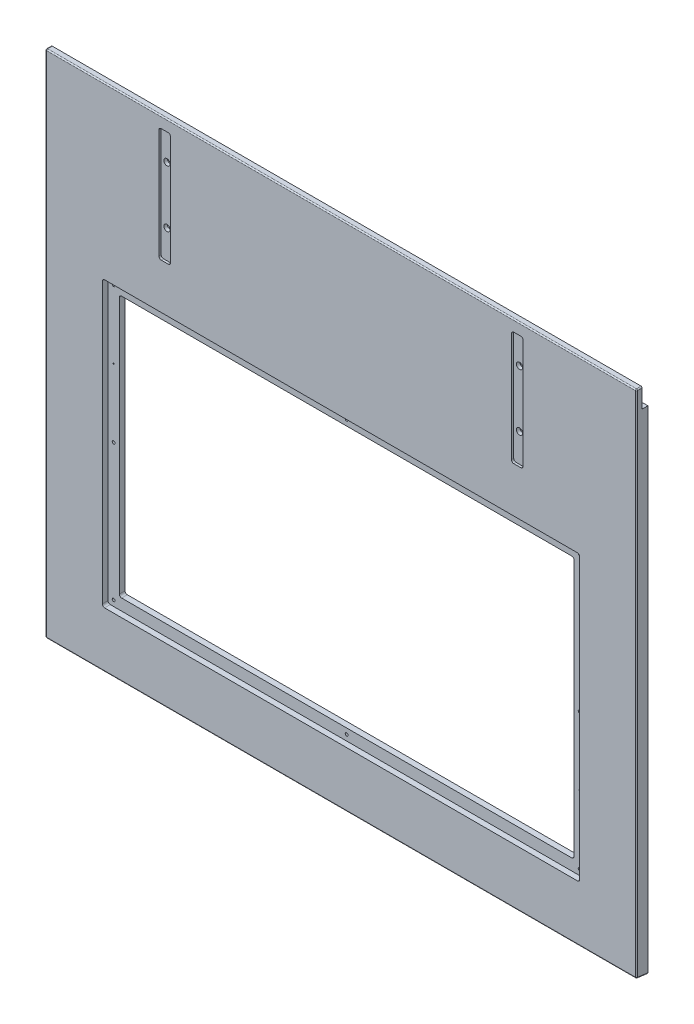
from build123d import *

# Parameters (mm, degrees)
SKETCH2_W                      = 520
SKETCH2_H                      = 450
BOSS_EXTRUDE2_DEPTH            = 10
SKETCH3_W                      = 10.2
SKETCH3_H                      = 100.2
CUT_EXTRUDE1_DEPTH             = 2
FILLET2_R                      = 2
CBORE_FOR_M5_SHCS1_D           = 5.5
CBORE_FOR_M5_SHCS1_CBORE_D     = 10
CBORE_FOR_M5_SHCS1_CBORE_DEPTH = 5
FILLET2_OF_MIRROR8_R           = 2
SKETCH7_W                      = 400
SKETCH7_H                      = 230
CUT_EXTRUDE3_DEPTH             = 469.828326789
FILLET3_R                      = 2
SKETCH9_W                      = 420
SKETCH9_H                      = 250
CUT_EXTRUDE5_DEPTH             = 5
FILLET4_R                      = 2
M3_TAPPED_HOLE1_D              = 2.5
CUT_EXTRUDE8_DEPTH             = 6
CUT_EXTRUDE7_DEPTH             = 469.828326789
CUT_EXTRUDE7_DEPTH_BACK        = 469.828326789
SKETCH11_W                     = 5
SKETCH11_H                     = 17
FILLET1_R                      = 1
M5X0_8_TAPPED_HOLE1_D          = 4.2
M5X0_8_TAPPED_HOLE1_DEPTH      = 8
M5X0_8_TAPPED_HOLE1_TIP        = 1.2618073
SKETCH17_W                     = 19
SKETCH17_H                     = 27
CUT_EXTRUDE9_DEPTH             = 2
FILLET5_R                      = 2
M4X0_7_TAPPED_HOLE1_AT_2_COUNT = 2
M4X0_7_TAPPED_HOLE1_AT_2_PITCH = 15
FILLET5_OF_MIRROR10_R          = 2
F_1_0MM_DOWEL_HOLE1_D          = 1
F_1_0MM_DOWEL_HOLE1_DEPTH      = 4
F_1_0MM_DOWEL_HOLE1_TIP        = 0.30043031


with BuildPart() as part:
    # Sketch2 → Boss-Extrude2 (new body)
    with BuildSketch(Plane.XY):
        with Locations((0, -165)):
            Rectangle(SKETCH2_W, SKETCH2_H)
    extrude(amount=-BOSS_EXTRUDE2_DEPTH)

    # Sketch3 → Cut-Extrude1 (cut)
    with BuildSketch(Plane.XY):
        with Locations((-155.1, 0)):
            Rectangle(SKETCH3_W, SKETCH3_H)
    cut_extrude1 = extrude(amount=-CUT_EXTRUDE1_DEPTH, mode=Mode.SUBTRACT)

    # Fillet2
    fillet2_edges = [part.edges().sort_by_distance(p)[0] for p in [
        (-160.2, -50.1, -1),
        (-150, -50.1, -1),
        (-150, 50.1, -1),
        (-160.2, 50.1, -1),
    ]]
    fillet(fillet2_edges, radius=FILLET2_R)

    # CBORE for M5 SHCS1 (through all)
    with Locations(Plane(origin=(0, 0, -10), x_dir=(-1, 0, 0), z_dir=(0, 0, -1))):
        with Locations((155.1, 25), (155.1, -25)):
            cbore_for_m5_shcs1 = CounterBoreHole(CBORE_FOR_M5_SHCS1_D / 2, CBORE_FOR_M5_SHCS1_CBORE_D / 2, CBORE_FOR_M5_SHCS1_CBORE_DEPTH)

    # Mirror8: Cut-Extrude1, CBORE for M5 SHCS1 across plane
    add(cut_extrude1.mirror(Plane(origin=(0, 0, 0), x_dir=(0, 0, 1), z_dir=(1, 0, 0))), mode=Mode.SUBTRACT)
    add(cbore_for_m5_shcs1.mirror(Plane(origin=(0, 0, 0), x_dir=(0, 0, 1), z_dir=(1, 0, 0))), mode=Mode.SUBTRACT)

    # Fillet2 of Mirror8
    fillet2_of_mirror8_edges = [part.edges().sort_by_distance(p)[0] for p in [
        (160.2, -50.1, -1),
        (150, -50.1, -1),
        (150, 50.1, -1),
        (160.2, 50.1, -1),
    ]]
    fillet(fillet2_of_mirror8_edges, radius=FILLET2_OF_MIRROR8_R)

    # Sketch7 → Cut-Extrude3 (cut, through all)
    with BuildSketch(Plane.XY):
        with Locations((0, -215)):
            Rectangle(SKETCH7_W, SKETCH7_H)
    extrude(amount=-CUT_EXTRUDE3_DEPTH, mode=Mode.SUBTRACT)

    # Fillet3
    fillet3_edges = [part.edges().sort_by_distance(p)[0] for p in [
        (200, -330, -5),
        (200, -100, -5),
        (-200, -330, -5),
        (-200, -100, -5),
    ]]
    fillet(fillet3_edges, radius=FILLET3_R)

    # Sketch9 → Cut-Extrude5 (cut)
    with BuildSketch(Plane.XY):
        with Locations((0, -215)):
            Rectangle(SKETCH9_W, SKETCH9_H)
    extrude(amount=-CUT_EXTRUDE5_DEPTH, mode=Mode.SUBTRACT)

    # Fillet4
    fillet4_edges = [part.edges().sort_by_distance(p)[0] for p in [
        (210, -90, -2.5),
        (210, -340, -2.5),
        (-210, -340, -2.5),
        (-210, -90, -2.5),
    ]]
    fillet(fillet4_edges, radius=FILLET4_R)

    # M3 Tapped Hole1 (through all)
    with Locations(Plane.XY.offset(-5)):
        with Locations((-205, -95), (0, -95), (-205, -215), (205, -95), (205, -215), (205, -335), (0, -335), (-205, -335)):
            Hole(M3_TAPPED_HOLE1_D / 2)

    # Sketch12 → Cut-Extrude8 (cut)
    with BuildSketch(Plane(origin=(0, 0, -10), x_dir=(-1, 0, 0), z_dir=(0, 0, -1))):
        with BuildLine():
            Line((10, -390), (-10, -390))
            Line((-10, -390), (-10, -386.5))
            ThreePointArc((-10, -386.5), (-9.267766953, -384.732233047), (-7.5, -384))
            Line((-7.5, -384), (7.5, -384))
            ThreePointArc((7.5, -384), (9.267766953, -384.732233047), (10, -386.5))
            Line((10, -386.5), (10, -390))
        make_face()
    extrude(amount=-CUT_EXTRUDE8_DEPTH, mode=Mode.SUBTRACT)

    # Sketch11 → Cut-Extrude7 (cut, two sides: drawn at the far end of the back side and taken through both)
    with BuildSketch(Plane(origin=(0, 0, 0), x_dir=(0, 0, -1), z_dir=(1, 0, 0)).offset(-CUT_EXTRUDE7_DEPTH_BACK)):
        Polygon((10, -390), (0, -388.685250563), (0, -390), align=None)
        with Locations((7.5, 51.5)):
            Rectangle(SKETCH11_W, SKETCH11_H)
    extrude(amount=CUT_EXTRUDE7_DEPTH + CUT_EXTRUDE7_DEPTH_BACK, mode=Mode.SUBTRACT)

    # Fillet1
    fillet1_edges = [part.edges().sort_by_distance(p)[0] for p in [
        (-260, 60, -2.5),
        (260, 60, -2.5),
        (260, -389.342625282, -5),
        (-260, -389.342625282, -5),
        (0, 60, 0),
        (-260, -164.342625282, 0),
        (0, -388.685250563, 0),
        (260, -164.342625282, 0),
    ]]
    fillet(fillet1_edges, radius=FILLET1_R)

    # M5x0.8 Tapped Hole1
    with Locations(Plane(origin=(0, 0, -10), x_dir=(-1, 0, 0), z_dir=(0, 0, -1))):
        with Locations((-215, 34), (-190, 34), (-12.5, 34), (12.5, 34), (190, 34), (215, 34)):
            Hole(M5X0_8_TAPPED_HOLE1_D / 2, depth=M5X0_8_TAPPED_HOLE1_DEPTH)
            with Locations((0, 0, -(M5X0_8_TAPPED_HOLE1_DEPTH + M5X0_8_TAPPED_HOLE1_TIP / 2))):  # 118° drill point
                Cone(0, M5X0_8_TAPPED_HOLE1_D / 2, M5X0_8_TAPPED_HOLE1_TIP, mode=Mode.SUBTRACT)

    # Sketch17 → Cut-Extrude9 (cut)
    with BuildSketch(Plane(origin=(0, 0, -10), x_dir=(-1, 0, 0), z_dir=(0, 0, -1))):
        with Locations((143.85, -376.5)):
            Rectangle(SKETCH17_W, SKETCH17_H)
    cut_extrude9 = extrude(amount=-CUT_EXTRUDE9_DEPTH, mode=Mode.SUBTRACT)

    # Fillet5
    fillet5_edges = [part.edges().sort_by_distance(p)[0] for p in [
        (-134.35, -363, -9),
        (-153.35, -363, -9),
    ]]
    fillet(fillet5_edges, radius=FILLET5_R)

    # Sketch19 → M4x0.7 Tapped Hole1 (revolve, cut)
    with BuildSketch(Plane(origin=(-143.85, -385, -8), x_dir=(0, 1, 0), z_dir=(1, 0, 0))):
        Polygon((0, 0), (0, 6.991420021), (1.65, 6), (1.65, 0), align=None)
    m4x0_7_tapped_hole1 = revolve(axis=Axis((-143.85, -385, -14.35), (0, 0, 1)), mode=Mode.SUBTRACT)

    # M4x0.7 Tapped Hole1 at 2: M4x0.7 Tapped Hole1 ×2
    with Locations(*[(0, i * M4X0_7_TAPPED_HOLE1_AT_2_PITCH, 0) for i in range(1, M4X0_7_TAPPED_HOLE1_AT_2_COUNT)]):
        add(m4x0_7_tapped_hole1, mode=Mode.SUBTRACT)

    # Mirror10: Cut-Extrude9, M4x0.7 Tapped Hole1 across plane
    add(cut_extrude9.mirror(Plane(origin=(0, 0, 0), x_dir=(0, 0, 1), z_dir=(1, 0, 0))), mode=Mode.SUBTRACT)
    add(m4x0_7_tapped_hole1.mirror(Plane(origin=(0, 0, 0), x_dir=(0, 0, 1), z_dir=(1, 0, 0))), mode=Mode.SUBTRACT)

    # Mirror10 copy 1 sketch → Mirror10 copy 1 (revolve, cut)
    with BuildSketch(Plane(origin=(143.85, -370, -8), x_dir=(0, 1, 0), z_dir=(-1, 0, 0))):
        Polygon((0, 0), (0, -6.991420021), (1.65, -6), (1.65, 0), align=None)
    revolve(axis=Axis((143.85, -370, -14.35), (0, 0, -1)), mode=Mode.SUBTRACT)

    # Fillet5 of Mirror10
    fillet5_of_mirror10_edges = [part.edges().sort_by_distance(p)[0] for p in [
        (134.35, -363, -9),
        (153.35, -363, -9),
    ]]
    fillet(fillet5_of_mirror10_edges, radius=FILLET5_OF_MIRROR10_R)

    # Ø1.0mm Dowel Hole1
    with Locations(Plane.XY.offset(-5)):
        with Locations((-205, -155), (205, -275)):
            Hole(F_1_0MM_DOWEL_HOLE1_D / 2, depth=F_1_0MM_DOWEL_HOLE1_DEPTH)
            with Locations((0, 0, -(F_1_0MM_DOWEL_HOLE1_DEPTH + F_1_0MM_DOWEL_HOLE1_TIP / 2))):  # 118° drill point
                Cone(0, F_1_0MM_DOWEL_HOLE1_D / 2, F_1_0MM_DOWEL_HOLE1_TIP, mode=Mode.SUBTRACT)


solid = part.part
